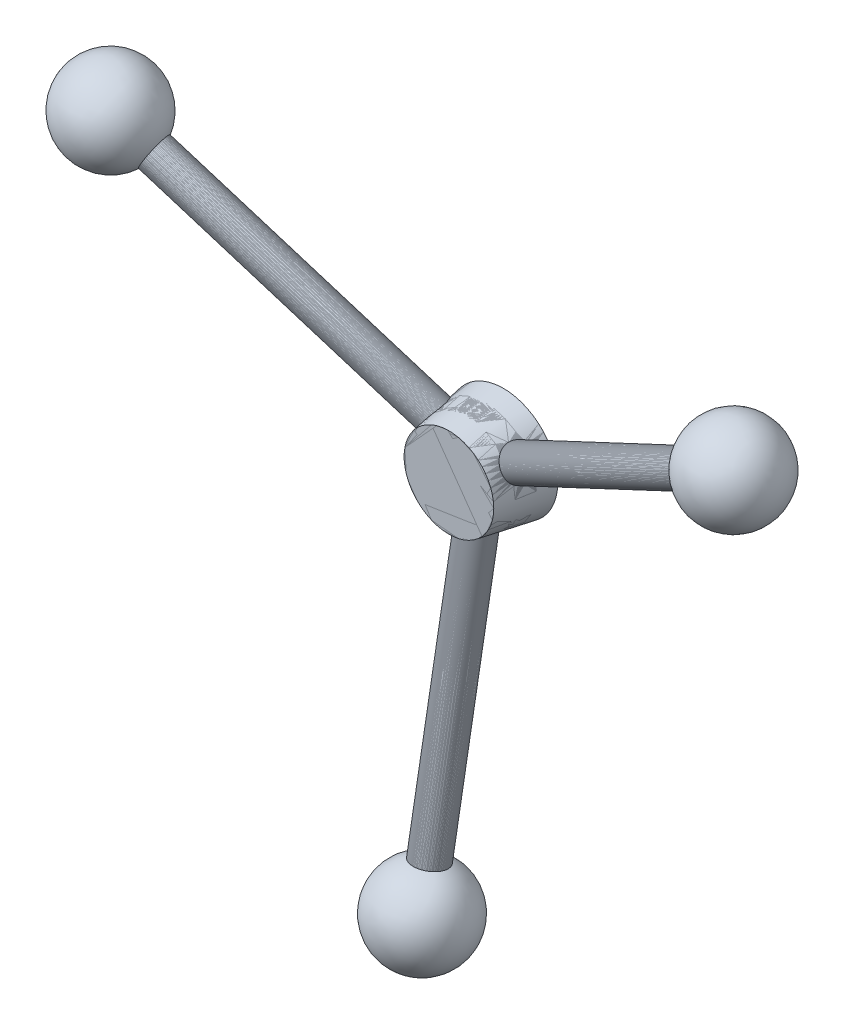
from build123d import *

# Parameters (mm, degrees)
SKETCH1_R                       = 10
BOSS_EXTRUDE1_DEPTH             = 10
BOSS_EXTRUDE1_TAPER             = 10
BOSS_EXTRUDE2_REACH             = 29.593
SKETCH7_R                       = 3
BOSS_EXTRUDE2_DIRECTION_2_DEPTH = 45
CIRPATTERN2_COUNT               = 3
SKETCH10_R                      = 2.5
CUT_EXTRUDE1_DEPTH              = 5
CIRPATTERN3_COUNT               = 3


with BuildPart() as part:
    # Sketch1 → Boss-Extrude1 (new body)
    with BuildSketch(Plane.XY):
        Circle(SKETCH1_R)
    extrude(amount=BOSS_EXTRUDE1_DEPTH, taper=BOSS_EXTRUDE1_TAPER)

    # Sketch7 → Boss-Extrude2 (add, up to next)
    with BuildSketch(Plane(origin=(0, -14.622501869, 2.578341605), x_dir=(-1, 0, 0), z_dir=(0, -0.9848077530122081, 0.1736481776669307)), mode=Mode.PRIVATE) as boss_extrude2_sk1:
        with Locations((0, -3.246024338)):
            Circle(SKETCH7_R)
    boss_extrude2_tool1 = extrude(boss_extrude2_sk1.sketch, amount=-BOSS_EXTRUDE2_REACH, mode=Mode.PRIVATE) - part.part
    boss_extrude2 = boss_extrude2_tool1.solids().sort_by_distance((0, -14.058836, 5.775052))[0]
    add(boss_extrude2)

    # Sketch7 → Boss-Extrude2 direction 2 (add)
    with BuildSketch(Plane(origin=(0, -14.622501869, 2.578341605), x_dir=(-1, 0, 0), z_dir=(0, -0.9848077530122081, 0.1736481776669307))):
        with Locations((0, -3.246024338)):
            Circle(SKETCH7_R)
    boss_extrude2_direction_2 = extrude(amount=BOSS_EXTRUDE2_DIRECTION_2_DEPTH)

    # CirPattern2: Boss-Extrude2, Boss-Extrude2 direction 2 ×3 about axis
    cirpattern2_axis = Axis((0, 0, 0), (0, 0, 1))
    add([boss_extrude2.rotate(cirpattern2_axis, i * 360 / CIRPATTERN2_COUNT) for i in range(1, CIRPATTERN2_COUNT)])
    add([boss_extrude2_direction_2.rotate(cirpattern2_axis, i * 360 / CIRPATTERN2_COUNT) for i in range(1, CIRPATTERN2_COUNT)])

    # Sketch10 → Cut-Extrude1 (cut)
    with BuildSketch(Plane(origin=(0, 0, 0), x_dir=(-1, 0, 0), z_dir=(0, 0, -1))):
        Circle(SKETCH10_R)
    extrude(amount=-CUT_EXTRUDE1_DEPTH, mode=Mode.SUBTRACT)

    # Sketch9 → Revolve1 (revolve)
    with BuildSketch(Plane(origin=(0, 0, 0), x_dir=(0, 0, -1), z_dir=(1, 0, 0))):
        with BuildLine():
            Line((-16.410451226, -74.375184544), (-13.589219534, -58.375184544))
            Line((-13.589219534, -58.375184544), (-16.543642793, -57.854240011))
            ThreePointArc((-16.543642793, -57.854240011), (-23.351855892, -66.170136867), (-16.410451226, -74.375184544))
        make_face()
    revolve(axis=Axis((0, -58.375184544, 13.589219534), (0, -0.984807753012208, 0.17364817766693058)))


with BuildPart() as cirpattern3_1:
    # CirPattern3: pattern copy
    add(part.part.rotate(Axis((0, 0, 0), (0, 0, -1)), 1 * 360 / CIRPATTERN3_COUNT))


with BuildPart() as cirpattern3_2:
    # CirPattern3: pattern copy
    add(part.part.rotate(Axis((0, 0, 0), (0, 0, -1)), 2 * 360 / CIRPATTERN3_COUNT))


solid = Compound([part.part, cirpattern3_1.part, cirpattern3_2.part])
